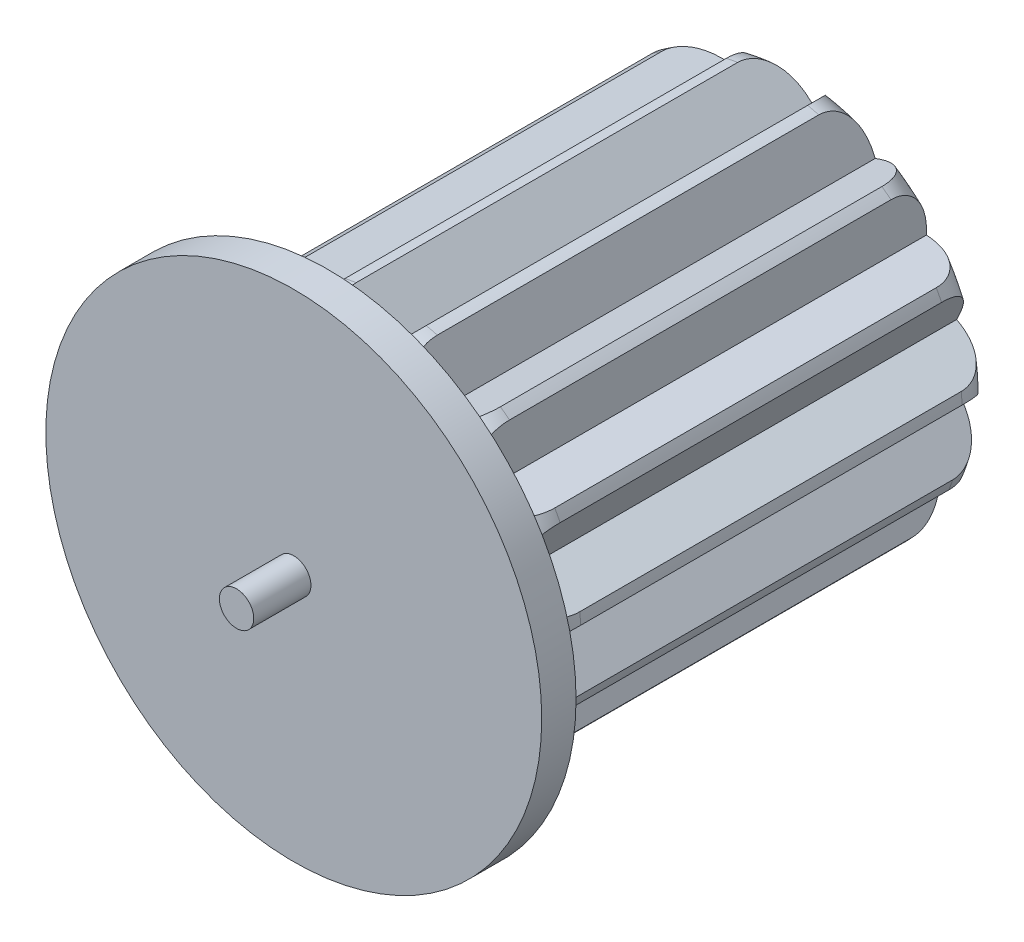
from build123d import *

# Parameters (mm, degrees)
SKETCH2_R           = 102.5
BOSS_EXTRUDE1_DEPTH = 250
FILLET1_R           = 30
FILLET2_R           = 20
CUT_EXTRUDE1_DEPTH  = 251
CIRPATTERN1_COUNT   = 15
SKETCH4_R           = 130
BOSS_EXTRUDE2_DEPTH = 18
SKETCH5_R           = 9
CUT_EXTRUDE2_DEPTH  = 171
SKETCH6_R           = 9
BOSS_EXTRUDE3_DEPTH = 30


with BuildPart() as part:
    # Sketch2 → Boss-Extrude1 (new body)
    with BuildSketch(Plane.XY):
        Circle(SKETCH2_R)
    extrude(amount=BOSS_EXTRUDE1_DEPTH)

    # Fillet1
    fillet1_edges = [part.edges().sort_by_distance(p)[0] for p in [
        (-102.5, 0, 250),
    ]]
    fillet(fillet1_edges, radius=FILLET1_R)

    # Fillet2
    fillet2_edges = [part.edges().sort_by_distance(p)[0] for p in [
        (-102.5, 0, 0),
    ]]
    fillet(fillet2_edges, radius=FILLET2_R)

    # Sketch3 → Cut-Extrude1 (cut, through all)
    with BuildSketch(Plane(origin=(0, 0, 0), x_dir=(-1, 0, 0), z_dir=(0, 0, -1))):
        Polygon((-50.13952447, 128.923184909), (-3.636168943, 82.419829382), (42.867186583, 128.923184909), align=None)
    cut_extrude1 = extrude(amount=-CUT_EXTRUDE1_DEPTH, mode=Mode.SUBTRACT)

    # CirPattern1: Cut-Extrude1 ×15 about axis
    cirpattern1_axis = Axis((0, 0, 0), (0, 0, 1))
    for i in range(1, CIRPATTERN1_COUNT):
        add(cut_extrude1.rotate(cirpattern1_axis, i * 360 / CIRPATTERN1_COUNT), mode=Mode.SUBTRACT)

    # Sketch4 → Boss-Extrude2 (add)
    with BuildSketch(Plane.XY.offset(250)):
        Circle(SKETCH4_R)
    extrude(amount=BOSS_EXTRUDE2_DEPTH)

    # Sketch5 → Cut-Extrude2 (cut)
    with BuildSketch(Plane.XY.offset(268)):
        Circle(SKETCH5_R)
    extrude(amount=-CUT_EXTRUDE2_DEPTH, mode=Mode.SUBTRACT)


with BuildPart() as body_2:
    # Sketch6 → Boss-Extrude3 (new body)
    with BuildSketch(Plane.XY.offset(268)):
        Circle(SKETCH6_R)
    extrude(amount=BOSS_EXTRUDE3_DEPTH)


solid = Compound([part.part, body_2.part])
